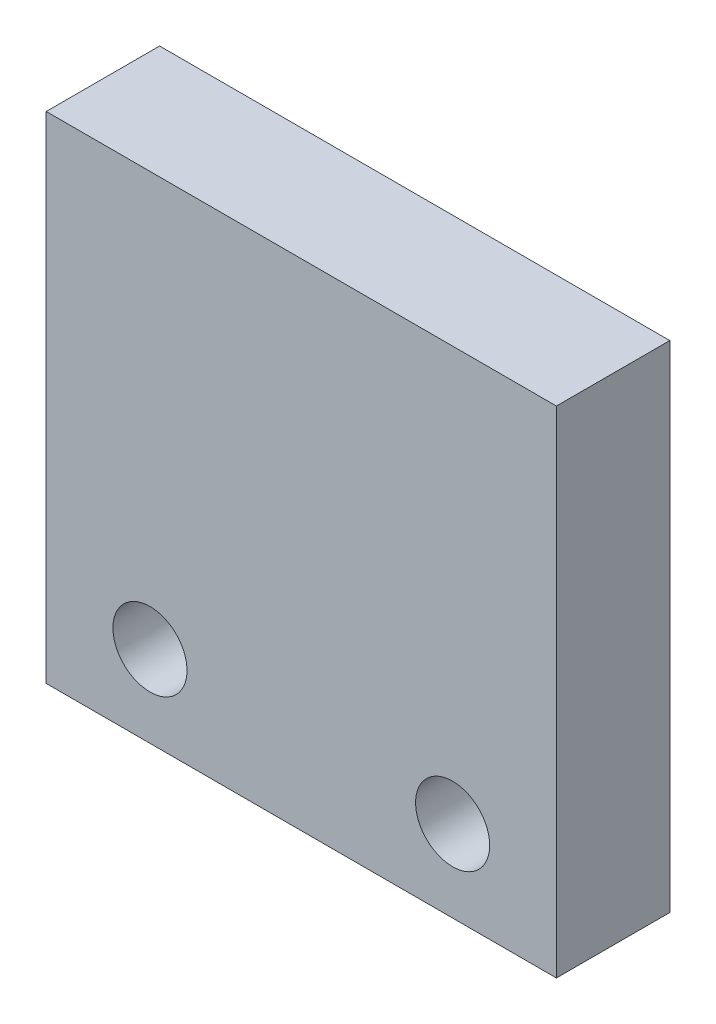
from build123d import *

# Parameters (mm, degrees)
SKETCH1_W           = 34.42
SKETCH1_H           = 33.42
SKETCH1_R           = 2.5
BOSS_EXTRUDE1_DEPTH = 7.65


with BuildPart() as part:
    # Sketch1 → Boss-Extrude1 (new body)
    with BuildSketch(Plane.XY):
        Rectangle(SKETCH1_W, SKETCH1_H)
        with Locations((10.21, -11.21)):
            Circle(SKETCH1_R, mode=Mode.SUBTRACT)
        with Locations((-10.21, -11.21)):
            Circle(SKETCH1_R, mode=Mode.SUBTRACT)
    extrude(amount=BOSS_EXTRUDE1_DEPTH)


solid = part.part
